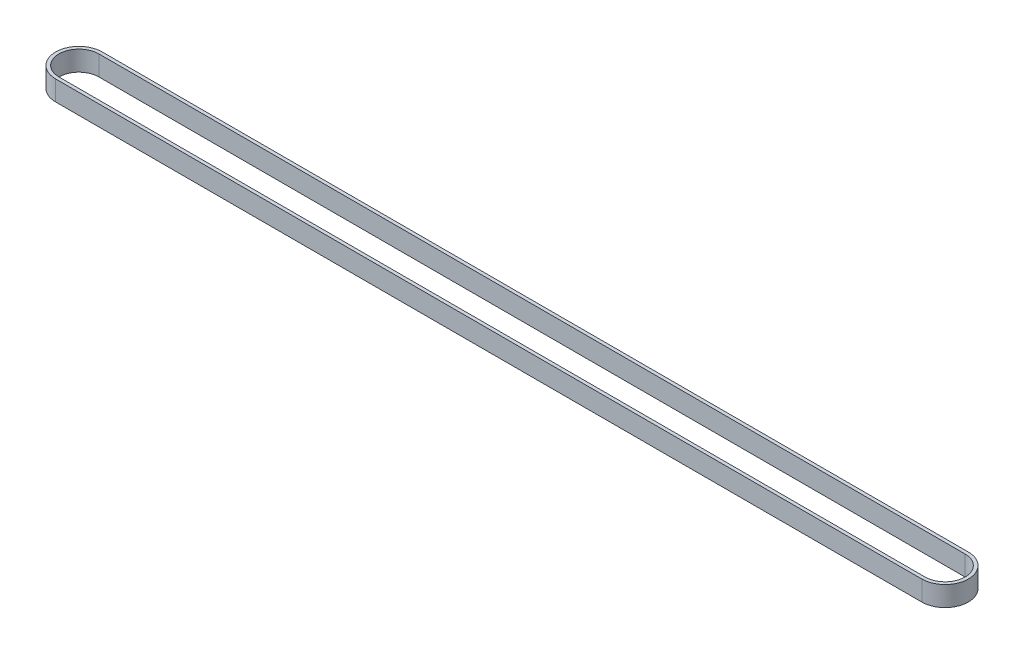
from build123d import *

# Parameters (mm, degrees)
BOSS_EXTRUDE1_DEPTH = 6


with BuildPart() as part:
    # Sketch1 → Boss-Extrude1 (new body)
    with BuildSketch(Plane(origin=(0, 0, 0), x_dir=(1, 0, 0), z_dir=(0, 1, 0))):
        with BuildLine():
            Line((0, 7), (260, 7))
            ThreePointArc((260, 7), (267, 0), (260, -7))
            Line((260, -7), (0, -7))
            ThreePointArc((0, -7), (-7, 0), (0, 7))
        make_face()
        with BuildLine():
            Line((0, 6), (260, 6))
            ThreePointArc((260, 6), (266, 0), (260, -6))
            Line((260, -6), (0, -6))
            ThreePointArc((0, -6), (-6, 0), (0, 6))
        make_face(mode=Mode.SUBTRACT)
    extrude(amount=BOSS_EXTRUDE1_DEPTH)


solid = part.part
